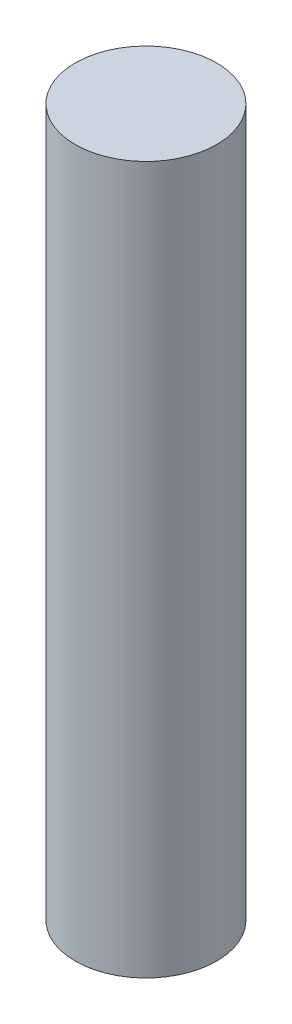
from build123d import *

# Parameters (mm, degrees)
SKETCH_1_R      = 5
EXTRUDE_1_DEPTH = 50


with BuildPart() as part:
    # 草图1 → 凸台-拉伸1 (new body)
    with BuildSketch(Plane(origin=(0, 0, 0), x_dir=(1, 0, 0), z_dir=(0, 1, 0))):
        Circle(SKETCH_1_R)
    extrude(amount=EXTRUDE_1_DEPTH)


solid = part.part
